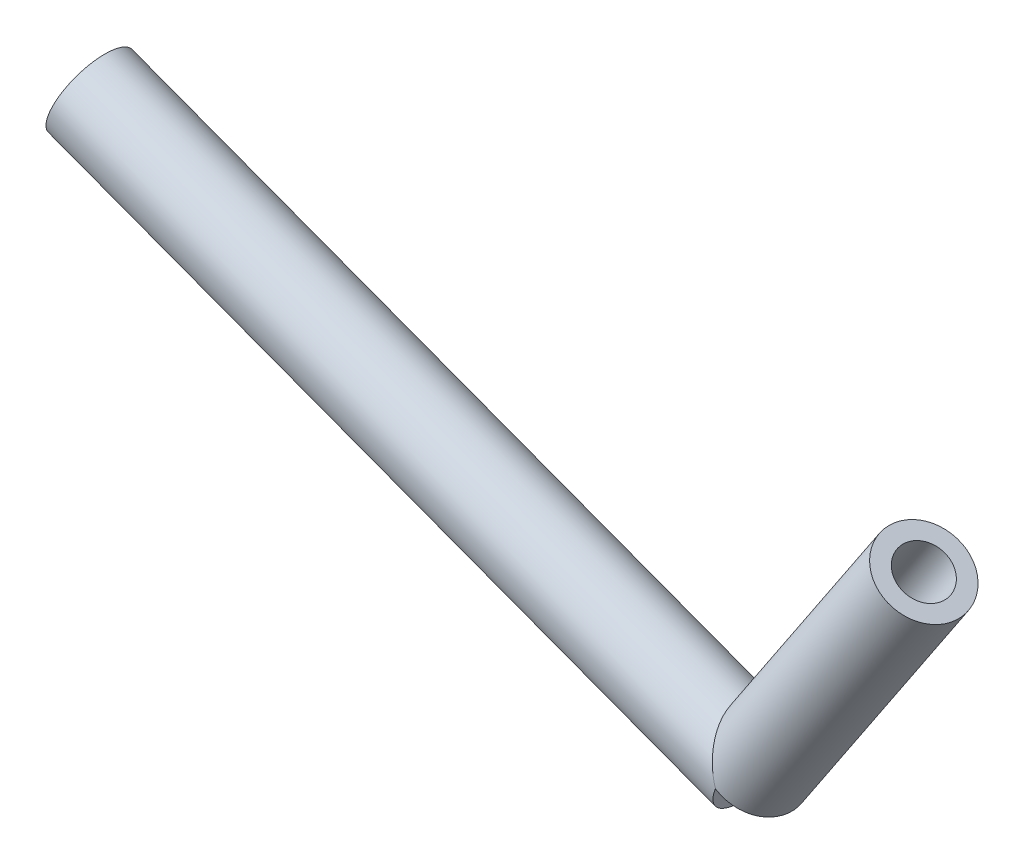
from build123d import *

# Parameters (mm, degrees)
SKETCH11_R                = 25
SKETCH11_R_2              = 15
PIPE_33_7_X_4_0_1_DEPTH   = 427.200187266
SKETCH11_ON_SEGMENT_2_R   = 25
SKETCH11_ON_SEGMENT_2_R_2 = 15
PIPE_33_7_X_4_0_1_2_DEPTH = 180.277563773


with BuildPart() as part:
    # Sketch11 → Pipe 33.7 X 4.0(1) (new body)
    with BuildSketch(Plane(origin=(-400, 0, 0), x_dir=(0.3511234415883917, 0.9363291775690447, 0), z_dir=(0.9363291775690447, -0.3511234415883917, 0))):
        Circle(SKETCH11_R)
        Circle(SKETCH11_R_2, mode=Mode.SUBTRACT)
    extrude(amount=PIPE_33_7_X_4_0_1_DEPTH)


with BuildPart() as body_2:
    # Sketch11 on segment 2 (carried to segment 2) → Pipe 33.7 X 4.0_1 2 (new body)
    with BuildSketch(Plane(origin=(0, -150, 0), x_dir=(-0.832050294, 0.554700196, 0), z_dir=(0.554700196, 0.832050294, 0))):
        Circle(SKETCH11_ON_SEGMENT_2_R)
        Circle(SKETCH11_ON_SEGMENT_2_R_2, mode=Mode.SUBTRACT)
    extrude(amount=PIPE_33_7_X_4_0_1_2_DEPTH)


solid = Compound([part.part, body_2.part])
